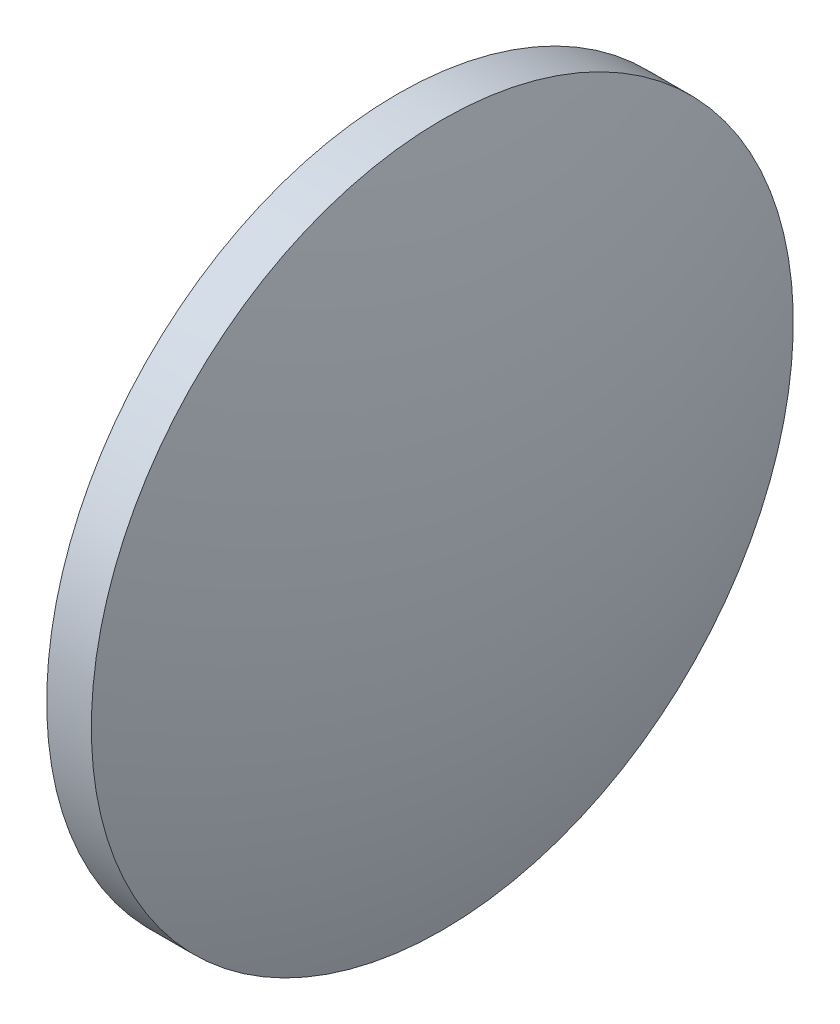
from build123d import *

# Parameters (mm, degrees)
SKETCH_1_ONE_SIDE_W = 1.59
SKETCH_1_ONE_SIDE_H = 12.5


with BuildPart() as part:
    # 草图1 one side → 旋转1 (revolve)
    with BuildSketch(Plane.XY):
        with Locations((85.096647416, 54.100504944)):
            Rectangle(SKETCH_1_ONE_SIDE_W, SKETCH_1_ONE_SIDE_H)
        with BuildLine():
            Line((82.346647416, 47.850504944), (84.301647416, 47.850504944))
            Line((84.301647416, 47.850504944), (84.301647416, 60.350504944))
            ThreePointArc((84.301647416, 60.350504944), (82.838350234, 54.176483623), (82.346647416, 47.850504944))
        make_face()
        with BuildLine():
            Line((85.891647416, 47.850504944), (87.846647416, 47.850504944))
            ThreePointArc((87.846647416, 47.850504944), (87.354944598, 54.176483623), (85.891647416, 60.350504944))
            Line((85.891647416, 60.350504944), (85.891647416, 47.850504944))
        make_face()
    revolve(axis=Axis((81.212969913, 47.850504944, 0), (1, 0, 0)))


solid = part.part
